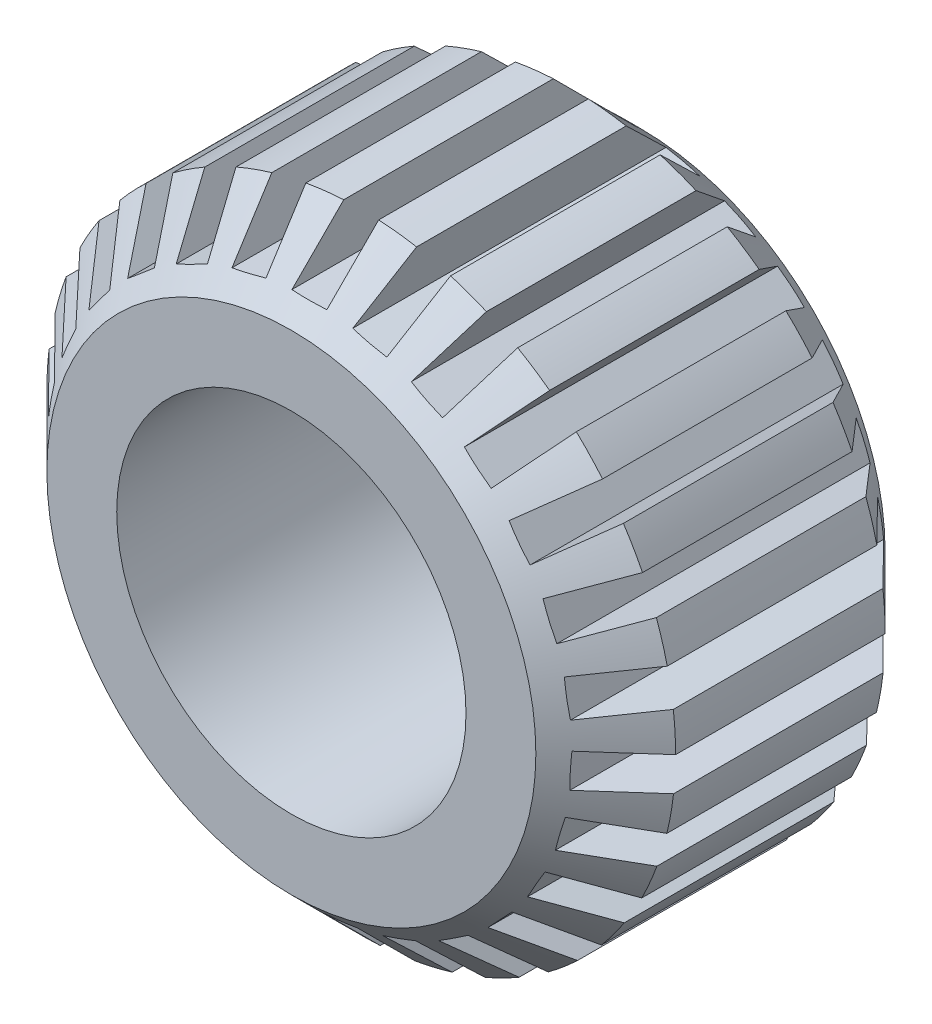
from build123d import *

# Parameters (mm, degrees)
SKETCH1_R           = 9
SKETCH1_R_2         = 5
BOSS_EXTRUDE1_DEPTH = 10
CHAMFER1_SIZE       = 2
CUT_EXTRUDE1_DEPTH  = 11
CIRPATTERN1_COUNT   = 27


with BuildPart() as part:
    # Sketch1 → Boss-Extrude1 (new body)
    with BuildSketch(Plane.XY):
        Circle(SKETCH1_R)
        Circle(SKETCH1_R_2, mode=Mode.SUBTRACT)
    extrude(amount=BOSS_EXTRUDE1_DEPTH)

    # Chamfer1
    chamfer1_edges = [part.edges().sort_by_distance(p)[0] for p in [
        (-9, 0, 0),
        (-9, 0, 10),
    ]]
    chamfer(chamfer1_edges, length=CHAMFER1_SIZE)

    # Sketch2 → Cut-Extrude1 (cut, through all)
    with BuildSketch(Plane.XY):
        with BuildLine():
            Line((0.5, 7.5), (0.5, 8.986100378))
            ThreePointArc((0.5, 8.986100378), (0, 9), (-0.5, 8.986100378))
            Line((-0.5, 8.986100378), (-0.5, 7.5))
            Line((-0.5, 7.5), (0.5, 7.5))
        make_face()
    cut_extrude1 = extrude(amount=CUT_EXTRUDE1_DEPTH, mode=Mode.SUBTRACT)

    # CirPattern1: Cut-Extrude1 ×27 about axis
    cirpattern1_axis = Axis((0, 0, 0), (0, 0, 1))
    for i in range(1, CIRPATTERN1_COUNT):
        add(cut_extrude1.rotate(cirpattern1_axis, i * 360 / CIRPATTERN1_COUNT), mode=Mode.SUBTRACT)


solid = part.part
